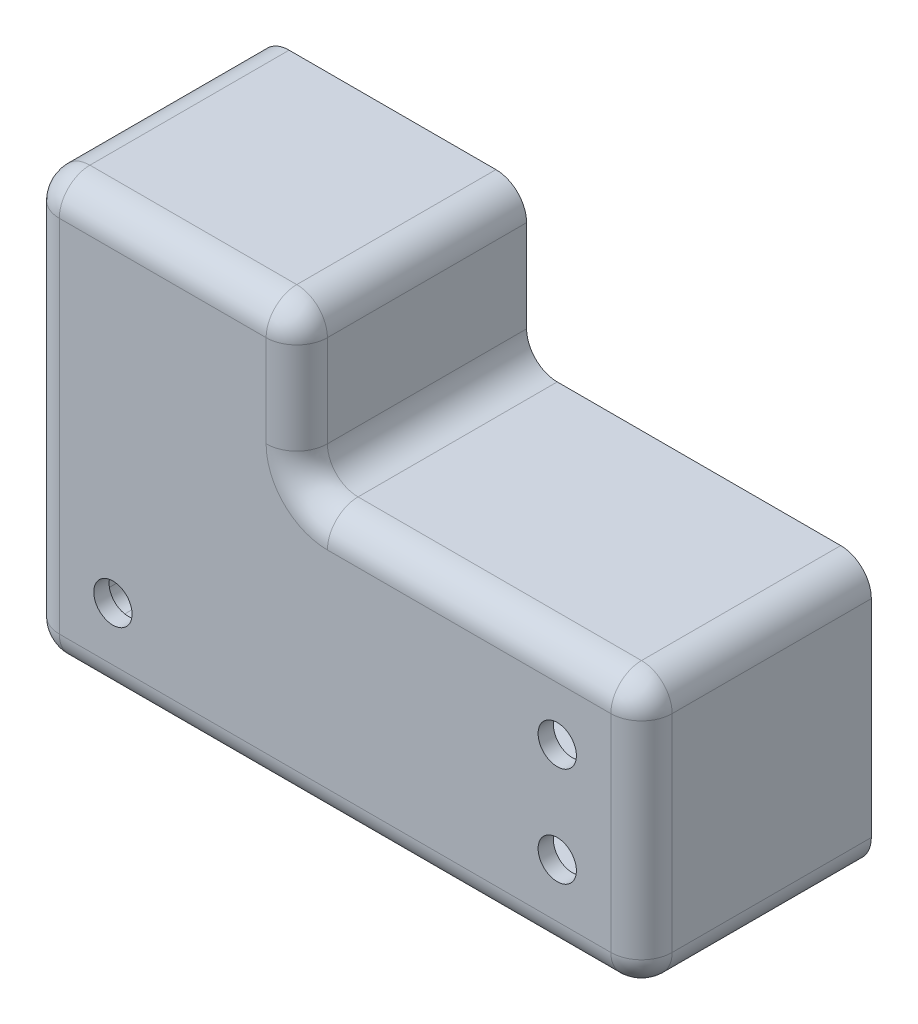
from build123d import *

# Parameters (mm, degrees)
BOSS_EXTRUDE1_DEPTH          = 38.1
FILLET1_R                    = 5.08
FILLET2_R                    = 5.08
SHELL1_T                     = -2.54
F_97_0_0059_DIAMETER_HOLE1_D = 6.35
F_1_4_0_25_DIAMETER_HOLE1_D  = 6.35


with BuildPart() as part:
    # Sketch1 → Boss-Extrude1 (new body)
    with BuildSketch(Plane.XY):
        Polygon((0, 0), (0, 69.85), (44.45, 69.85), (44.45, 44.45), (101.6, 44.45), (101.6, 0), align=None)
    extrude(amount=BOSS_EXTRUDE1_DEPTH)

    # Fillet1
    fillet1_edges = [part.edges().sort_by_distance(p)[0] for p in [
        (0, 0, 19.05),
        (0, 69.85, 19.05),
        (44.45, 69.85, 19.05),
        (44.45, 44.45, 19.05),
        (101.6, 44.45, 19.05),
        (101.6, 0, 19.05),
    ]]
    fillet(fillet1_edges, radius=FILLET1_R)

    # Fillet2
    fillet2_edges = [part.edges().sort_by_distance(p)[0] for p in [
        (101.6, 22.225, 38.1),
        (50.8, 0, 38.1),
        (73.025, 44.45, 38.1),
        (44.45, 57.15, 38.1),
        (22.225, 69.85, 38.1),
        (0, 34.925, 38.1),
        (42.962102448, 68.362102448, 38.1),
        (1.487897552, 68.362102448, 38.1),
        (1.487897552, 1.487897552, 38.1),
        (100.112102448, 42.962102448, 38.1),
        (100.112102448, 1.487897552, 38.1),
        (45.937897552, 45.937897552, 38.1),
    ]]
    fillet(fillet2_edges, radius=FILLET2_R)

    # Shell1
    shell1_openings = [part.faces().sort_by_distance(p)[0] for p in [
        (48.683333333, 38.1, 0),
    ]]
    offset(amount=SHELL1_T, openings=shell1_openings, kind=Kind.INTERSECTION)

    # #97 (0.0059) Diameter Hole1 (through all)
    with Locations(Plane.XY.offset(38.1)):
        with Locations((87.63, 30.48)):
            Hole(F_97_0_0059_DIAMETER_HOLE1_D / 2)

    # 1/4 (0.25) Diameter Hole1 (through all)
    with Locations(Plane.XY.offset(38.1)):
        with Locations((87.63, 13.97), (13.97, 13.97)):
            Hole(F_1_4_0_25_DIAMETER_HOLE1_D / 2)


solid = part.part
